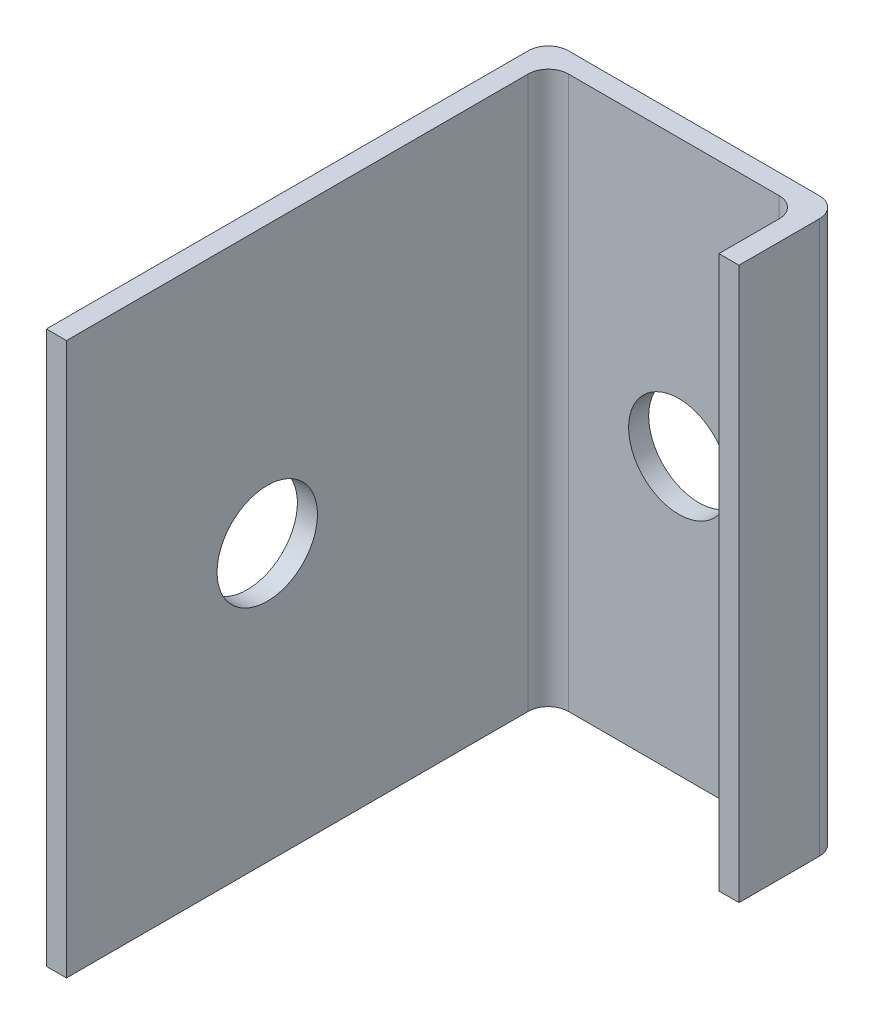
from build123d import *

# Parameters (mm, degrees)
BOSS_EXTRUDE1_DEPTH              = 55
M10X1_0_TAPPED_HOLE2_D           = 9
M10X1_0_TAPPED_HOLE2_DEPTH       = 23
M10X1_0_TAPPED_HOLE2_CBORE_D     = 10
M10X1_0_TAPPED_HOLE2_CBORE_DEPTH = 20
M10X1_0_TAPPED_HOLE2_TIP         = 2.703872786
M10X1_0_TAPPED_HOLE1_D           = 9
M10X1_0_TAPPED_HOLE1_DEPTH       = 23
M10X1_0_TAPPED_HOLE1_CBORE_D     = 10
M10X1_0_TAPPED_HOLE1_CBORE_DEPTH = 20
M10X1_0_TAPPED_HOLE1_TIP         = 2.703872786


with BuildPart() as part:
    # Sketch1 → Boss-Extrude1 (new body)
    with BuildSketch(Plane(origin=(0, 0, 0), x_dir=(1, 0, 0), z_dir=(0, 1, 0))):
        with BuildLine():
            Line((-61.161397451, -27.487824391), (-61.161397451, 20.512175609))
            ThreePointArc((-61.161397451, 20.512175609), (-60.575611013, 21.926389171), (-59.161397451, 22.512175609))
            Line((-59.161397451, 22.512175609), (-34.161397451, 22.512175609))
            ThreePointArc((-34.161397451, 22.512175609), (-32.747183888, 21.926389171), (-32.161397451, 20.512175609))
            Line((-32.161397451, 20.512175609), (-32.161397451, 12.512175609))
            Line((-32.161397451, 12.512175609), (-34.161397451, 12.512175609))
            Line((-34.161397451, 12.512175609), (-34.161397451, 18.512175609))
            ThreePointArc((-34.161397451, 18.512175609), (-34.747183888, 19.926389171), (-36.161397451, 20.512175609))
            Line((-36.161397451, 20.512175609), (-57.161397451, 20.512175609))
            ThreePointArc((-57.161397451, 20.512175609), (-58.575611013, 19.926389171), (-59.161397451, 18.512175609))
            Line((-59.161397451, 18.512175609), (-59.161397451, -27.487824391))
            Line((-59.161397451, -27.487824391), (-61.161397451, -27.487824391))
        make_face()
    extrude(amount=BOSS_EXTRUDE1_DEPTH)

    # M10x1.0 Tapped Hole2
    with Locations(Plane(origin=(-46.161397451, 27.5, -22.512175609), x_dir=(-1, 0, 0), z_dir=(0, 0, -1))):
        with Locations((0, 0)):
            CounterBoreHole(M10X1_0_TAPPED_HOLE2_D / 2, M10X1_0_TAPPED_HOLE2_CBORE_D / 2, M10X1_0_TAPPED_HOLE2_CBORE_DEPTH, depth=M10X1_0_TAPPED_HOLE2_DEPTH)
            with Locations((0, 0, -(M10X1_0_TAPPED_HOLE2_DEPTH + M10X1_0_TAPPED_HOLE2_TIP / 2))):  # 118° drill point
                Cone(0, M10X1_0_TAPPED_HOLE2_D / 2, M10X1_0_TAPPED_HOLE2_TIP, mode=Mode.SUBTRACT)

    # M10x1.0 Tapped Hole1
    with Locations(Plane(origin=(-61.161397451, 27.5, 7.487824391), x_dir=(0, 0, -1), z_dir=(-1, 0, 0))):
        with Locations((0, 0)):
            CounterBoreHole(M10X1_0_TAPPED_HOLE1_D / 2, M10X1_0_TAPPED_HOLE1_CBORE_D / 2, M10X1_0_TAPPED_HOLE1_CBORE_DEPTH, depth=M10X1_0_TAPPED_HOLE1_DEPTH)
            with Locations((0, 0, -(M10X1_0_TAPPED_HOLE1_DEPTH + M10X1_0_TAPPED_HOLE1_TIP / 2))):  # 118° drill point
                Cone(0, M10X1_0_TAPPED_HOLE1_D / 2, M10X1_0_TAPPED_HOLE1_TIP, mode=Mode.SUBTRACT)


solid = part.part
